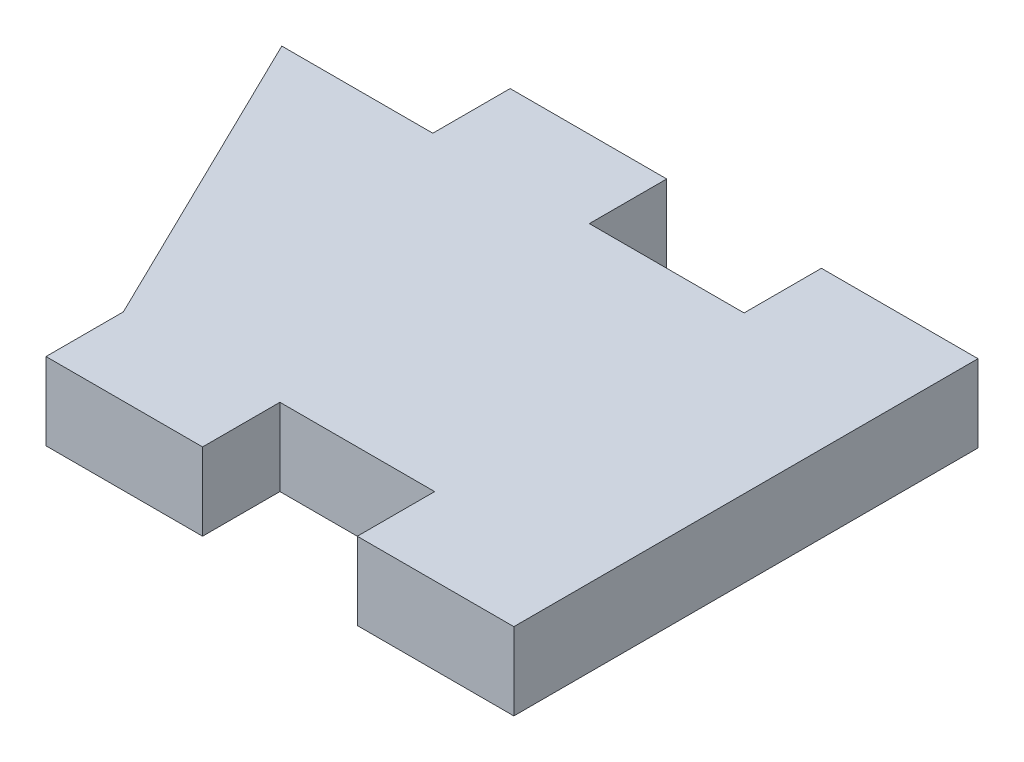
from build123d import *

# Parameters (mm, degrees)
SKETCH1_W           = 25.4
SKETCH1_H           = 12.7
BOSS_EXTRUDE1_DEPTH = 3.175
SKETCH2_W           = 6.4262
SKETCH2_H           = 3.175
BOSS_EXTRUDE2_DEPTH = 3.175
CUT_EXTRUDE1_DEPTH  = 3.175


with BuildPart() as part:
    # Sketch1 → Boss-Extrude1 (new body)
    with BuildSketch(Plane(origin=(0, 0, 0), x_dir=(1, 0, 0), z_dir=(0, 1, 0))):
        Rectangle(SKETCH1_W, SKETCH1_H)
    extrude(amount=BOSS_EXTRUDE1_DEPTH)

    # Sketch2 → Boss-Extrude2 (add)
    with BuildSketch(Plane.XY.offset(6.35)):
        with Locations((9.4869, 1.5875)):
            Rectangle(SKETCH2_W, SKETCH2_H)
        with Locations((-3.2893, 1.5875)):
            Rectangle(SKETCH2_W, SKETCH2_H)
    boss_extrude2 = extrude(amount=BOSS_EXTRUDE2_DEPTH)

    # Mirror1: Boss-Extrude2 across plane
    add(boss_extrude2.mirror(Plane.XY))

    # Sketch3 → Cut-Extrude1 (cut)
    with BuildSketch(Plane(origin=(0, 3.175, 0), x_dir=(1, 0, 0), z_dir=(0, 1, 0))):
        Polygon((-6.5024, -6.35), (-12.7, 6.35), (-12.7, -6.35), align=None)
    extrude(amount=-CUT_EXTRUDE1_DEPTH, mode=Mode.SUBTRACT)


solid = part.part
